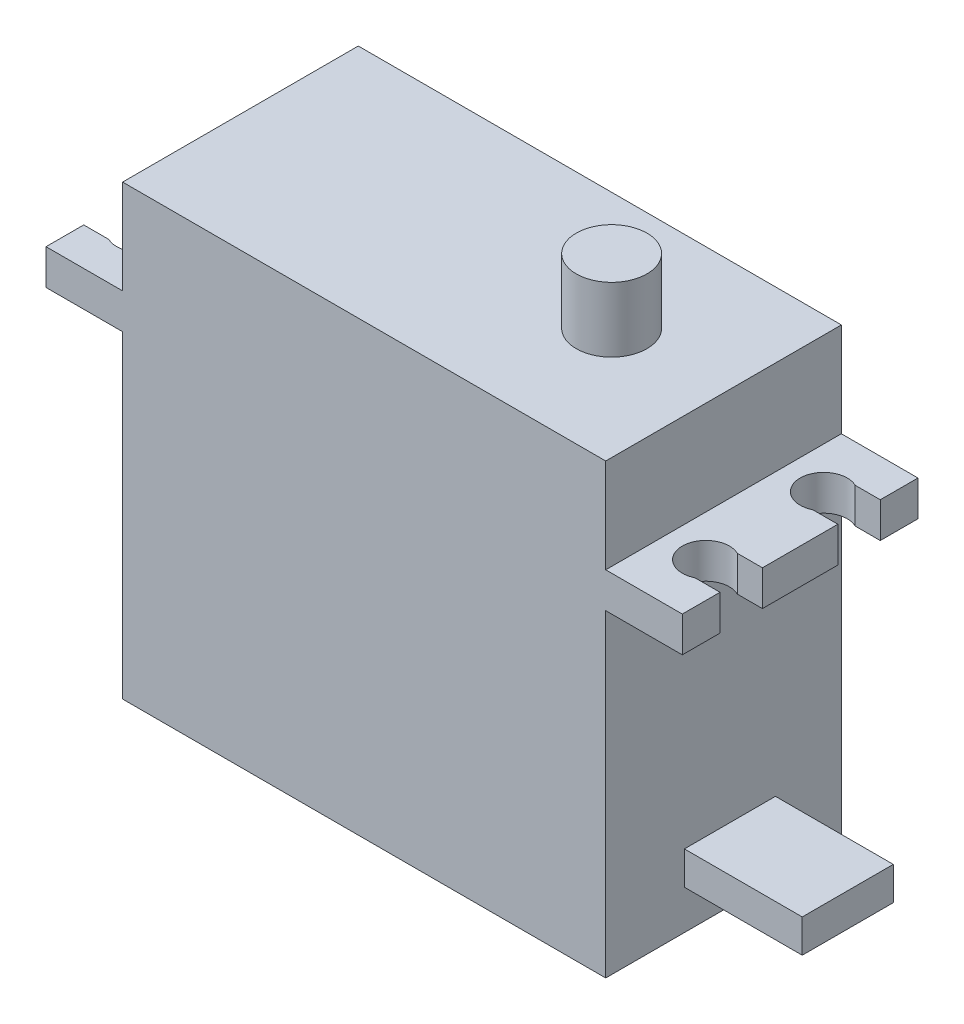
from build123d import *

# Parameters (mm, degrees)
SKETCH_1_W          = 41
SKETCH_1_H          = 20
EXTRUDE_1_DEPTH     = 38
SKETCH_2_W          = 54
SKETCH_2_H          = 20
EXTRUDE_2_DEPTH     = 3
CUT_EXTRUDE_1_REACH = 43.581
SKETCH_4_R          = 7.5
EXTRUDE_3_DEPTH     = 3
SKETCH_5_R          = 3
EXTRUDE_4_DEPTH     = 5.5
SKETCH_6_W          = 7.726872992
SKETCH_6_H          = 2.816336885
EXTRUDE_5_DEPTH     = 10


with BuildPart() as part:
    # 草圖1 → 伸長1 (new body)
    with BuildSketch(Plane(origin=(0, 0, 0), x_dir=(1, 0, 0), z_dir=(0, 1, 0))):
        Rectangle(SKETCH_1_W, SKETCH_1_H)
    extrude(amount=EXTRUDE_1_DEPTH)

    # 草圖2 → 伸長2 (add)
    with BuildSketch(Plane(origin=(0, 27, 0), x_dir=(-1, 0, 0), z_dir=(0, 1, 0))):
        Rectangle(SKETCH_2_W, SKETCH_2_H)
    extrude(amount=EXTRUDE_2_DEPTH)

    # 草圖3 → 除料-伸長1 (cut, up to next)
    with BuildSketch(Plane(origin=(0, 30, 0), x_dir=(-1, 0, 0), z_dir=(0, 1, 0)), mode=Mode.PRIVATE) as cut_extrude_1_sk1:
        with BuildLine():
            Line((-27, 3.2), (-24.871779789, 3.2))
            ThreePointArc((-24.871779789, 3.2), (-22, 5), (-24.871779789, 6.8))
            Line((-24.871779789, 6.8), (-27, 6.8))
            Line((-27, 6.8), (-27, 3.2))
        make_face()
    cut_extrude_1_tool1 = extrude(cut_extrude_1_sk1.sketch, amount=-CUT_EXTRUDE_1_REACH, mode=Mode.PRIVATE) & part.part
    # 草圖3 → 除料-伸長1 (cut, up to next)
    with BuildSketch(Plane(origin=(0, 30, 0), x_dir=(-1, 0, 0), z_dir=(0, 1, 0)), mode=Mode.PRIVATE) as cut_extrude_1_sk2:
        with BuildLine():
            Line((-27, -6.8), (-24.871779789, -6.8))
            ThreePointArc((-24.871779789, -6.8), (-22, -5), (-24.871779789, -3.2))
            Line((-24.871779789, -3.2), (-27, -3.2))
            Line((-27, -3.2), (-27, -6.8))
        make_face()
    cut_extrude_1_tool2 = extrude(cut_extrude_1_sk2.sketch, amount=-CUT_EXTRUDE_1_REACH, mode=Mode.PRIVATE) & part.part
    # 草圖3 → 除料-伸長1 (cut, up to next)
    with BuildSketch(Plane(origin=(0, 30, 0), x_dir=(-1, 0, 0), z_dir=(0, 1, 0)), mode=Mode.PRIVATE) as cut_extrude_1_sk3:
        with BuildLine():
            Line((27, -3.2), (24.871779789, -3.2))
            ThreePointArc((24.871779789, -3.2), (22, -5), (24.871779789, -6.8))
            Line((24.871779789, -6.8), (27, -6.8))
            Line((27, -6.8), (27, -3.2))
        make_face()
    cut_extrude_1_tool3 = extrude(cut_extrude_1_sk3.sketch, amount=-CUT_EXTRUDE_1_REACH, mode=Mode.PRIVATE) & part.part
    # 草圖3 → 除料-伸長1 (cut, up to next)
    with BuildSketch(Plane(origin=(0, 30, 0), x_dir=(-1, 0, 0), z_dir=(0, 1, 0)), mode=Mode.PRIVATE) as cut_extrude_1_sk4:
        with BuildLine():
            Line((27, 6.8), (24.871779789, 6.8))
            ThreePointArc((24.871779789, 6.8), (22, 5), (24.871779789, 3.2))
            Line((24.871779789, 3.2), (27, 3.2))
            Line((27, 3.2), (27, 6.8))
        make_face()
    cut_extrude_1_tool4 = extrude(cut_extrude_1_sk4.sketch, amount=-CUT_EXTRUDE_1_REACH, mode=Mode.PRIVATE) & part.part
    add(cut_extrude_1_tool1.solids().sort_by_distance((24.63194, 30, 5))[0], mode=Mode.SUBTRACT)
    add(cut_extrude_1_tool2.solids().sort_by_distance((24.63194, 30, -5))[0], mode=Mode.SUBTRACT)
    add(cut_extrude_1_tool3.solids().sort_by_distance((-24.63194, 30, -5))[0], mode=Mode.SUBTRACT)
    add(cut_extrude_1_tool4.solids().sort_by_distance((-24.63194, 30, 5))[0], mode=Mode.SUBTRACT)

    # 草圖4 → 伸長3 (add)
    with BuildSketch(Plane(origin=(0, 30, 0), x_dir=(-1, 0, 0), z_dir=(0, 1, 0))):
        with Locations((-11, 0)):
            Circle(SKETCH_4_R)
    extrude(amount=EXTRUDE_3_DEPTH)

    # 草圖5 → 伸長4 (add)
    with BuildSketch(Plane(origin=(0, 38, 0), x_dir=(-1, 0, 0), z_dir=(0, 1, 0))):
        with Locations(Location((-11, 0, 0), (0, 0, 90))):
            Circle(SKETCH_5_R)
    extrude(amount=EXTRUDE_4_DEPTH)

    # 草圖6 → 伸長5 (add)
    with BuildSketch(Plane(origin=(20.5, 0, 0), x_dir=(0, 0, -1), z_dir=(1, 0, 0))):
        with Locations((0.541603247, 4.740833757)):
            Rectangle(SKETCH_6_W, SKETCH_6_H)
    extrude(amount=EXTRUDE_5_DEPTH)


solid = part.part
